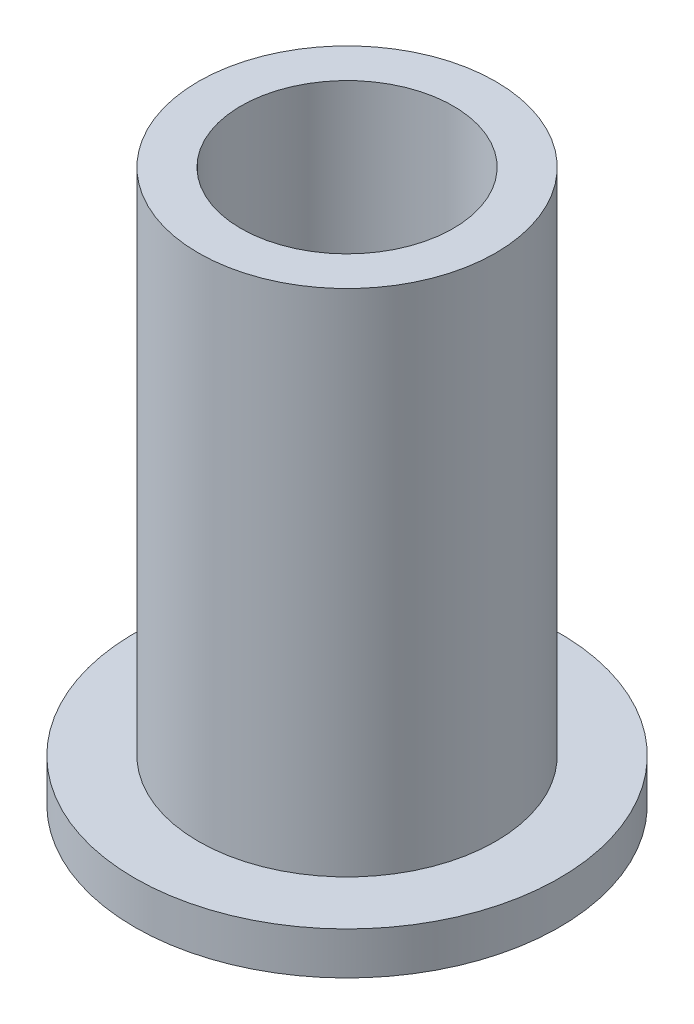
from build123d import *

# Parameters (mm, degrees)
SKETCH1_R           = 5
BOSS_EXTRUDE1_DEPTH = 1
SKETCH2_R           = 3.5
BOSS_EXTRUDE2_DEPTH = 12
SKETCH3_R           = 2.5
CUT_EXTRUDE1_DEPTH  = 13


with BuildPart() as part:
    # Sketch1 → Boss-Extrude1 (new body)
    with BuildSketch(Plane(origin=(0, 0, 0), x_dir=(1, 0, 0), z_dir=(0, 1, 0))):
        Circle(SKETCH1_R)
    extrude(amount=BOSS_EXTRUDE1_DEPTH)

    # Sketch2 → Boss-Extrude2 (add)
    with BuildSketch(Plane(origin=(0, 1, 0), x_dir=(1, 0, 0), z_dir=(0, 1, 0))):
        Circle(SKETCH2_R)
    extrude(amount=BOSS_EXTRUDE2_DEPTH)

    # Sketch3 → Cut-Extrude1 (cut)
    with BuildSketch(Plane(origin=(0, 13, 0), x_dir=(1, 0, 0), z_dir=(0, 1, 0))):
        Circle(SKETCH3_R)
    extrude(amount=-CUT_EXTRUDE1_DEPTH, mode=Mode.SUBTRACT)


solid = part.part
